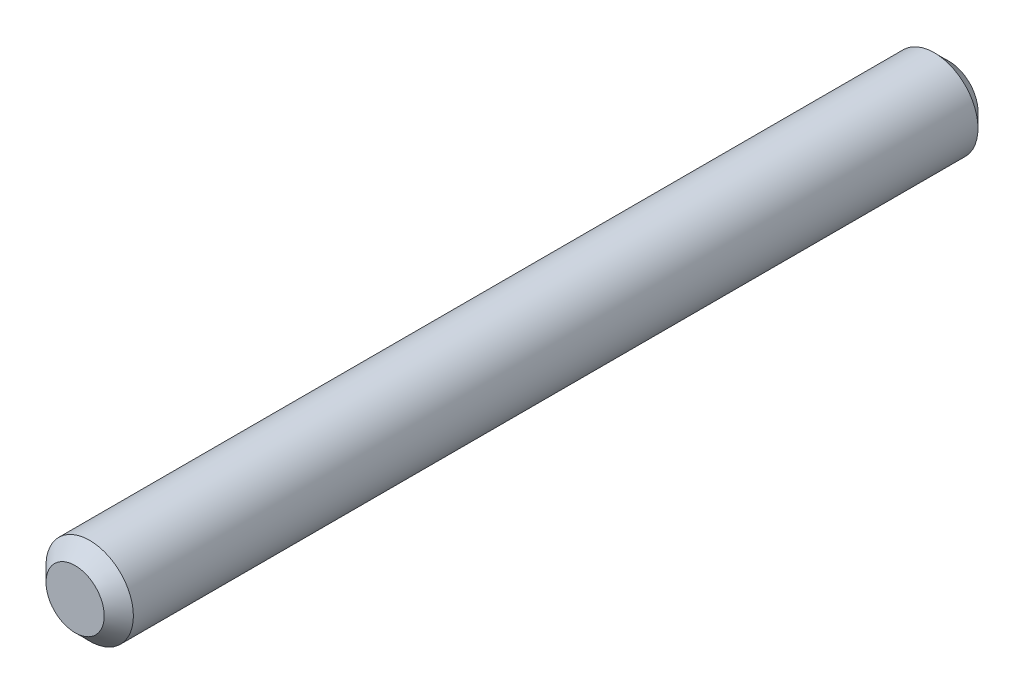
from build123d import *

# Parameters (mm, degrees)
SKETCH1_R           = 3
BOSS_EXTRUDE1_DEPTH = 30
CHAMFER1_SIZE       = 1
CHAMFER2_SIZE       = 1


with BuildPart() as part:
    # Sketch1 → Boss-Extrude1 (new body, symmetric)
    with BuildSketch(Plane.XY):
        Circle(SKETCH1_R)
    extrude(amount=BOSS_EXTRUDE1_DEPTH, both=True)

    # Chamfer1
    chamfer1_edges = [part.edges().sort_by_distance(p)[0] for p in [
        (-3, 0, 30),
    ]]
    chamfer(chamfer1_edges, length=CHAMFER1_SIZE)

    # Chamfer2
    chamfer2_edges = [part.edges().sort_by_distance(p)[0] for p in [
        (-3, 0, -30),
    ]]
    chamfer(chamfer2_edges, length=CHAMFER2_SIZE)


solid = part.part
